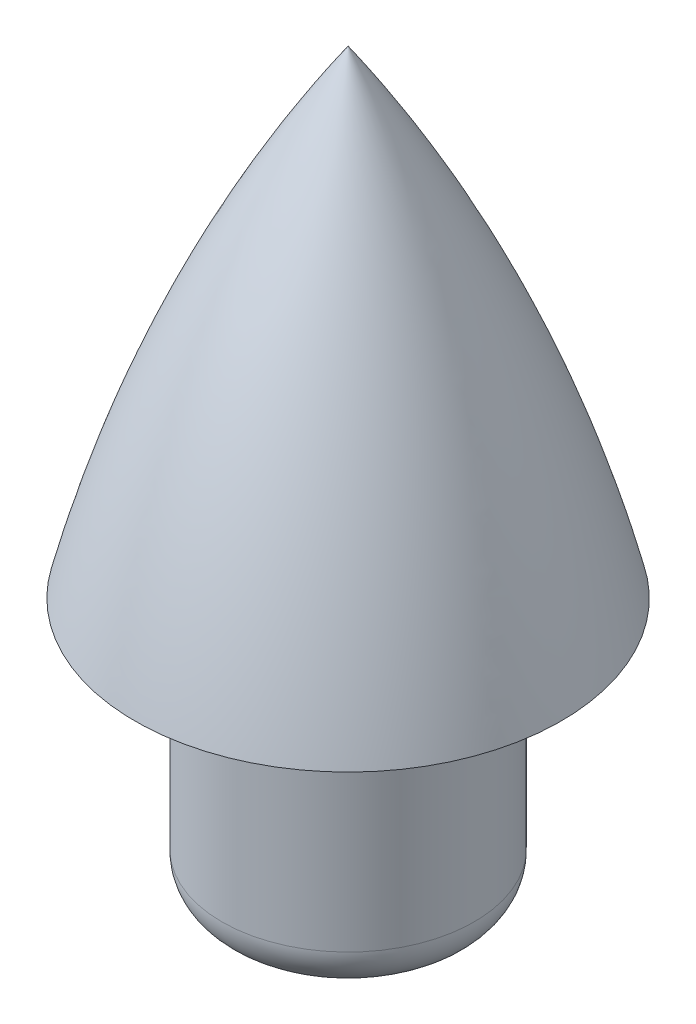
from build123d import *

# Parameters (mm, degrees)
ESBO_O1_R                = 14.5
RESSALTO_EXTRUS_O1_DEPTH = 30
FILETE1_R                = 5


with BuildPart() as part:
    # Esboço1 → Ressalto-extrusão1 (new body)
    with BuildSketch(Plane(origin=(0, 0, 0), x_dir=(1, 0, 0), z_dir=(0, 1, 0))):
        Circle(ESBO_O1_R)
    extrude(amount=RESSALTO_EXTRUS_O1_DEPTH)

    # Esboço3 → Revolução2 (revolve)
    with BuildSketch(Plane.XY):
        with BuildLine():
            Line((0, 30), (0, 85))
            ThreePointArc((0, 85), (14.704360861, 58.593306202), (24.5, 30))
            Line((24.5, 30), (0, 30))
        make_face()
    revolve(axis=Axis((0, 30, 0), (0, 1, 0)))

    # Filete1
    filete1_edges = [part.edges().sort_by_distance(p)[0] for p in [
        (-14.5, 0, 0),
    ]]
    fillet(filete1_edges, radius=FILETE1_R)


solid = part.part
